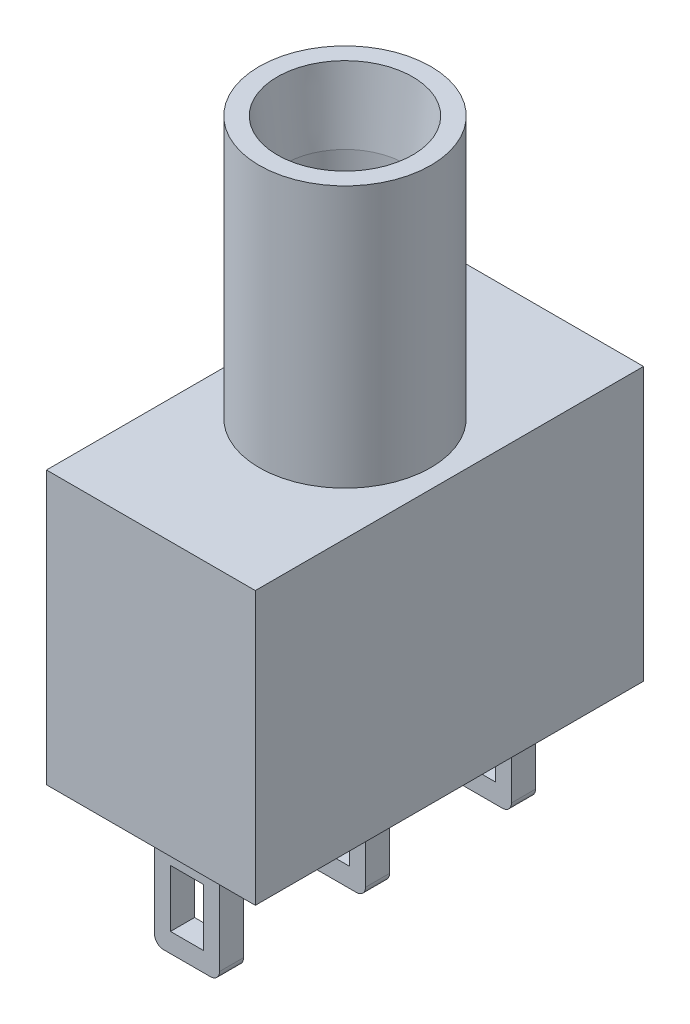
from build123d import *

# Parameters (mm, degrees)
ESQUISSE1_W                  = 6.94
ESQUISSE1_H                  = 12.9
BOSS_EXTRU_1_DEPTH           = 9.06
ESQUISSE2_R                  = 2.85
BOSS_EXTRU_2_DEPTH           = 8.7
ESQUISSE3_R                  = 2
ENL_V_MAT_EXTRU_1_DEPTH      = 8.7
ENL_V_START                  = -3.45
ESQUISSE4_R                  = 0.5
ENL_V_MAT_EXTRU_2_DEPTH      = 2.5
ENL_V_MAT_EXTRU_2_DEPTH_BACK = 2.5
CHANFREIN1_SIZE              = 0.25
CHANFREIN1_SIZE2             = 2.378591114
ESQUISSE5_W                  = 2.16
ESQUISSE5_H                  = 0.8
BOSS_EXTRU_3_DEPTH           = 4
CONG_1_R                     = 0.3
ESQUISSE6_W                  = 1.1
ESQUISSE6_H                  = 1.9
ENL_V_MAT_EXTRU_3_DEPTH      = 12.7
SCALE1_SCALE                 = 0.64015


with BuildPart() as part:
    # Esquisse1 → Boss.-Extru.1 (new body)
    with BuildSketch(Plane(origin=(0, 0, 0), x_dir=(1, 0, 0), z_dir=(0, 1, 0))):
        with Locations((3.47, 6.45)):
            Rectangle(ESQUISSE1_W, ESQUISSE1_H)
    extrude(amount=BOSS_EXTRU_1_DEPTH)

    # Esquisse2 → Boss.-Extru.2 (add)
    with BuildSketch(Plane(origin=(0, 9.06, 0), x_dir=(1, 0, 0), z_dir=(0, 1, 0))):
        with Locations((3.47, 6.45)):
            Circle(ESQUISSE2_R)
    extrude(amount=BOSS_EXTRU_2_DEPTH)

    # Esquisse3 → Enlèv. mat.-Extru.1 (cut)
    with BuildSketch(Plane(origin=(0, 17.76, 0), x_dir=(1, 0, 0), z_dir=(0, 1, 0))):
        with Locations((3.47, 6.45)):
            Circle(ESQUISSE3_R)
    extrude(amount=-ENL_V_MAT_EXTRU_1_DEPTH, mode=Mode.SUBTRACT)

    # Esquisse4 → Enlèv. mat.-Extru.2 (cut, two sides)
    with BuildSketch(Plane.ZY.offset(ENL_V_START)) as enl_v_mat_extru_2_sk:
        with Locations((-6.453279692, 14.76)):
            Circle(ESQUISSE4_R)
    extrude(amount=ENL_V_MAT_EXTRU_2_DEPTH, mode=Mode.SUBTRACT)
    extrude(enl_v_mat_extru_2_sk.sketch, amount=-ENL_V_MAT_EXTRU_2_DEPTH_BACK, mode=Mode.SUBTRACT)

    # Chanfrein1
    chanfrein1_edges = [part.edges().sort_by_distance(p)[0] for p in [
        (1.47, 17.76, -6.45),
    ]]
    chanfrein1_side = [part.faces().sort_by_distance(p)[0] for p in [
        (0.700610173, 17.76, -6.45),
    ]]
    chamfer(chanfrein1_edges, length=CHANFREIN1_SIZE, length2=CHANFREIN1_SIZE2, reference=chanfrein1_side[0])

    # Esquisse5 → Boss.-Extru.3 (add)
    with BuildSketch(Plane.XZ):
        with Locations((3.47, -1.6)):
            Rectangle(ESQUISSE5_W, ESQUISSE5_H)
        with Locations((3.47, -11.3)):
            Rectangle(ESQUISSE5_W, ESQUISSE5_H)
        with Locations((3.47, -6.45)):
            Rectangle(ESQUISSE5_W, ESQUISSE5_H)
    extrude(amount=BOSS_EXTRU_3_DEPTH)

    # Congé1
    cong_1_edges = [part.edges().sort_by_distance(p)[0] for p in [
        (2.39, -4, -1.6),
        (4.55, -4, -1.6),
        (4.55, -4, -11.3),
        (2.39, -4, -11.3),
        (2.39, -4, -6.45),
        (4.55, -4, -6.45),
    ]]
    fillet(cong_1_edges, radius=CONG_1_R)

    # Esquisse6 → Enlèv. mat.-Extru.3 (cut, through all)
    with BuildSketch(Plane(origin=(0, 0, -11.7), x_dir=(-1, 0, 0), z_dir=(0, 0, -1))):
        with Locations((-3.470290463, -2.41)):
            Rectangle(ESQUISSE6_W, ESQUISSE6_H)
    extrude(amount=-ENL_V_MAT_EXTRU_3_DEPTH, mode=Mode.SUBTRACT)


with BuildPart() as part_1:
    # Scale1: scaled about (3.47008246, 5.432983417, -6.449996817)
    add(part.part.scale(SCALE1_SCALE).moved(Location((1.248709173, 1.955059083, -2.321031355))))


solid = part_1.part
